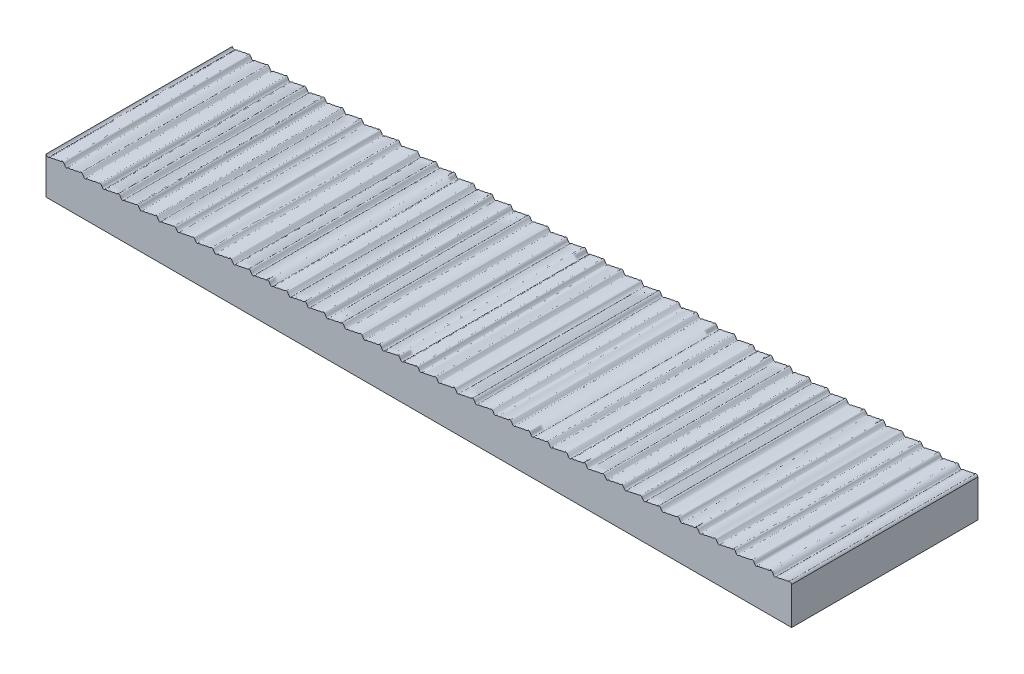
from build123d import *

# Parameters (mm, degrees)
AUFSATZ_LINEAR_AUSTRAGEN1_DEPTH = 50


with BuildPart() as part:
    # Skizze1 → Aufsatz-Linear austragen1 (new body)
    with BuildSketch(Plane.XY):
        with BuildLine():
            Line((0, 10), (0, 0))
            Line((0, 0), (200, 0))
            Line((200, 0), (200, 10))
            add(Edge.make_bspline(
                [(0, 10), (0.032006504, 9.947251725), (0.096257273, 9.839130988), (0.234909001, 9.611414135), (0.499662737, 9.425076683), (0.843522161, 9.651124983), (1.112437897, 9.835883165), (1.501650386, 9.736238413), (1.805748065, 9.815309142), (2.054364451, 9.941510427), (2.305494291, 10.007611652), (2.578672342, 9.99534574), (2.877842259, 10.015980332), (3.189051168, 10.200216604), (3.548975528, 10.264656199), (4.006052231, 10.149740183), (4.283292665, 10.532842136), (4.70199408, 10.516818743), (4.882215848, 10.161704391), (5.060681148, 9.933910956), (5.199674852, 9.631251905), (5.506445935, 9.411278935), (5.820888943, 9.640877582), (6.091719409, 9.814635092), (6.458189596, 9.755166071), (6.796212128, 9.786573828), (7.119360934, 9.996462894), (7.488800036, 10.003383695), (7.858830243, 9.993648069), (8.19220552, 10.208222573), (8.540894832, 10.250582735), (8.949614043, 10.173687554), (9.214558457, 10.416007843), (9.580028868, 10.587783918), (9.843255258, 10.271931735), (9.998865934, 10.002190322), (10.156265981, 9.727950643), (10.423156059, 9.406839859), (10.788569526, 9.590006508), (11.055060475, 9.822527482), (11.449757984, 9.75198322), (11.794839609, 9.786834881), (12.124601512, 9.99796634), (12.493867467, 10.002466767), (12.863746765, 9.995305922), (13.196790371, 10.211052702), (13.546238484, 10.249166052), (13.954813763, 10.174346647), (14.218309579, 10.421386455), (14.586305585, 10.585924869), (14.845207018, 10.266320448), (15.002081262, 9.998726175), (15.158240093, 9.722236402), (15.429499905, 9.405226405), (15.792242493, 9.595384618), (16.060219144, 9.823030322), (16.455035893, 9.75075919), (16.799292223, 9.789289436), (17.129237167, 9.999939729), (17.498560828, 10.001143074), (17.868527928, 9.997386953), (18.199879635, 10.212724455), (18.552541759, 10.24914575), (18.955719966, 10.172836242), (19.223228528, 10.427316624), (19.592237888, 10.583742354), (19.847243084, 10.26082626), (20.005237888, 9.995261693), (20.160246492, 9.716510947), (20.43584548, 9.403781209), (20.79585148, 9.600724987), (21.065439586, 9.823474914), (21.460285139, 9.749528548), (21.803937226, 9.7918642), (22.133929111, 10.001897517), (22.503936402, 9.999910088), (22.873274711, 9.999338831), (23.204548574, 10.215354943), (23.557907755, 10.247756035), (23.960818974, 10.173573184), (24.227019016, 10.432661195), (24.598402046, 10.581580395), (24.849117158, 10.255360884), (25.00842879, 9.991822389), (25.16225555, 9.710769778), (25.442200713, 9.402503704), (25.799399192, 9.606028807), (26.070703013, 9.823848426), (26.465506362, 9.748329946), (26.808583447, 9.794484213), (27.138630105, 10.003795563), (27.509306886, 9.998679315), (27.87800526, 10.001347533), (28.20921081, 10.217931096), (28.563280997, 10.24633683), (28.965848264, 10.174401049), (29.230849402, 10.437974877), (29.604499382, 10.57927456), (29.850962716, 10.249968515), (30.01160145, 9.988392506), (30.164288173, 9.70501997), (30.448553492, 9.401390586), (30.802893507, 9.611294102), (31.076004936, 9.824151827), (31.470702058, 9.747164541), (31.813229902, 9.79714856), (32.143341397, 10.005633237), (32.514672058, 9.997452481), (32.882720389, 10.003412166), (33.213866689, 10.220452414), (33.568662197, 10.244889377), (33.970807964, 10.175320484), (34.234721349, 10.443254274), (34.610528232, 10.576827865), (34.852782892, 10.2446498), (35.014754443, 9.984969669), (35.166346129, 9.699264863), (35.454901561, 9.400439093), (35.806335276, 9.616520525), (36.081348032, 9.824380909), (36.475864776, 9.746044568), (36.817892677, 9.799834446), (37.148033402, 10.007451205), (37.52008768, 9.996155468), (37.887318995, 10.00567065), (38.218701879, 10.222665356), (38.573720388, 10.243871409), (38.976264247, 10.175536109), (39.240682486, 10.452714148), (39.63069245, 10.575993721), (39.866524321, 10.211625688), (40.038261817, 9.958540442), (40.192105017, 9.637425717), (40.516755211, 9.403915112), (40.835542888, 9.659766155), (41.110808095, 9.814575398), (41.492912913, 9.748386662), (41.825623928, 9.803614948), (42.152961569, 10.009790072), (42.525340169, 9.994608817), (42.892067423, 10.008023777), (43.223298761, 10.224978386), (43.57917124, 10.242424005), (43.981013403, 10.176612548), (44.244730396, 10.457962252), (44.636451549, 10.572950322), (44.868179201, 10.206540324), (45.041190165, 9.955296565), (45.194610516, 9.63163098), (45.522883436, 9.404672173), (45.838727237, 9.66425471), (46.116375986, 9.814626257), (46.497835276, 9.7473727), (46.830324953, 9.806461319), (47.157694931, 10.011363491), (47.530656578, 9.993515394), (47.896832636, 10.010065931), (48.227755182, 10.227659484), (48.5849172, 10.240315518), (48.985192422, 10.178823417), (49.245896669, 10.457675642), (49.624367556, 10.568251335), (49.854430915, 10.236912858), (50.018828067, 9.981069239), (50.16602851, 9.698190142), (50.457686522, 9.400520554), (50.809516387, 9.615688099), (51.085907118, 9.829027423), (51.490397123, 9.741234621), (51.829282122, 9.808194156), (52.163129179, 10.01202536), (52.535628561, 9.992818249), (52.901695338, 10.01207691), (53.232284965, 10.23010355), (53.590387807, 10.238687664), (53.989864633, 10.180157454), (54.249941388, 10.462759024), (54.630143428, 10.56537252), (54.856224017, 10.23184705), (55.021946657, 9.977597647), (55.168121767, 9.692491152), (55.463956001, 9.399652915), (55.813099517, 9.621171333), (56.091222935, 9.828898971), (56.495555261, 9.740291735), (56.833891822, 9.811022957), (57.167921739, 10.013579132), (57.540960558, 9.991622376), (57.906347312, 10.014414893), (58.236919824, 10.232341643), (58.595811507, 10.237118366), (58.994501386, 10.181542877), (59.254021541, 10.467812169), (59.635852245, 10.562357705), (59.858000604, 10.22685641), (60.025040742, 9.974128005), (60.170246509, 9.686791865), (60.47021242, 9.39893872), (60.816633001, 9.626621924), (61.096582329, 9.828704093), (61.500685751, 9.739387323), (61.838506137, 9.81389124), (62.172726416, 10.015069339), (62.546289783, 9.990440558), (62.910987899, 10.016803239), (63.241552422, 10.234523139), (63.601247651, 10.235527922), (63.999072962, 10.183022763), (64.258151841, 10.472814033), (64.64148673, 10.559218744), (64.8597674, 10.221935058), (65.028107334, 9.970661043), (65.172405755, 9.681093113), (65.476453034, 9.3983772), (65.820119762, 9.632036163), (66.101983594, 9.828445037), (66.505789816, 9.73852177), (66.843124991, 9.81679828), (67.177543964, 10.016495498), (67.551616529, 9.989274474), (67.915618038, 10.019240979), (68.246183563, 10.236647951), (68.606697143, 10.233917395), (69.003580617, 10.184597619), (69.262333703, 10.477762024), (69.647046328, 10.555958347), (69.861527334, 10.217082084), (70.031145399, 9.967194935), (70.174601832, 9.675396607), (70.48267563, 9.397967002), (70.823562549, 9.637410917), (71.107425211, 9.82812376), (71.51086862, 9.737695613), (71.847748379, 9.819743235), (72.182375094, 10.017857214), (72.55694115, 9.988125762), (72.920238675, 10.021727146), (73.25081416, 10.238716053), (73.612160836, 10.232287767), (74.008025898, 10.186268078), (74.266568295, 10.482653455), (74.652531021, 10.552579474), (74.863282502, 10.212295667), (75.034155979, 9.963729641), (75.176833084, 9.6697003), (75.488884915, 9.397712934), (75.8269504, 9.642730602), (76.112927215, 9.827761935), (76.515927187, 9.736857693), (76.85257986, 9.822843125), (77.187301465, 10.019153241), (77.563005295, 9.987116026), (77.924920278, 10.024097941), (78.256907569, 10.241787102), (78.618032277, 10.229501821), (79.01020157, 10.187182783), (79.271726339, 10.487852673), (79.657383553, 10.548899091), (79.865344146, 10.207712749), (80.036981914, 9.96019081), (80.179168024, 9.664039377), (80.495033877, 9.397586942), (80.830335836, 9.648027517), (81.118430129, 9.827315577), (81.520971165, 9.736115182), (81.857207079, 9.825862098), (82.192183116, 10.020389304), (82.568324847, 9.98599945), (82.92957705, 10.026699464), (83.261510916, 10.243738176), (83.623650779, 10.227839022), (84.014541356, 10.1890433), (84.276044683, 10.492620728), (84.662728148, 10.545294425), (84.867093003, 10.203055696), (85.039933116, 9.956717079), (85.181487399, 9.658358599), (85.501191096, 9.397622383), (85.833664215, 9.65326698), (86.123983001, 9.826818789), (86.525985707, 9.735410389), (86.861842942, 9.828918057), (87.197078339, 10.021558938), (87.573643321, 9.984905248), (87.934227757, 10.029347537), (88.266113659, 10.24562967), (88.629288515, 10.226163226), (89.018828242, 10.191001978), (89.28041781, 10.497325227), (89.667998685, 10.54157848), (89.868845109, 10.198461429), (90.042854, 9.953236479), (90.183851213, 9.652686735), (90.507325927, 9.397802147), (90.836954453, 9.658459119), (91.129579527, 9.826262743), (91.530981444, 9.734751727), (91.866568907, 9.832008601), (92.202024048, 10.022754973), (92.57927551, 9.983709242), (92.938887147, 10.032295526), (93.271412763, 10.247371771), (93.634698941, 10.224684825), (94.024438526, 10.193019481), (94.284228129, 10.500966232), (94.672836498, 10.538947466), (94.870983673, 10.192894324), (95.045474313, 9.950893312), (95.186451893, 9.645352944), (95.513216956, 9.400765749), (95.840590578, 9.658352355), (96.134673857, 9.833470046), (96.57393839, 9.709236266), (96.957302379, 9.908745983), (97.40270625, 10.048956494), (97.928024772, 9.950545397), (98.349048217, 10.370609416), (98.939332984, 10.05474952), (99.271360932, 10.562376312), (99.739708775, 10.498649332), (99.914320879, 10.10260444), (100.085437404, 9.897448643), (100.253409945, 9.513710136), (100.708786446, 9.426753666), (101.034006655, 9.929697391), (101.602809116, 9.642202071), (102.029671442, 10.005115914), (102.541602513, 9.984815941), (102.992435817, 10.04024688), (103.365631293, 10.290547322), (103.763984642, 10.183377678), (104.091381715, 10.263408161), (104.334474016, 10.528669736), (104.679584539, 10.505757555), (104.849646517, 10.231328695), (105.00991329, 9.998075433), (105.141182041, 9.748181714), (105.471987687, 9.317868095), (105.890747355, 9.762249419), (106.304062235, 9.803711789), (106.822914218, 9.738108925), (107.197672748, 10.080986538), (107.686468421, 9.932823858), (108.083521136, 10.139724741), (108.471321242, 10.285040613), (108.932790429, 10.142546045), (109.216105566, 10.430918395), (109.589600053, 10.57543281), (109.831379568, 10.283226944), (109.987121524, 10.023935445), (110.122963481, 9.787208471), (110.459770924, 9.300129694), (110.891396856, 9.782048104), (111.342971404, 9.774611498), (111.879621083, 9.781247689), (112.301756379, 10.099789764), (112.819437594, 9.917828042), (113.191614997, 10.240818263), (113.592405759, 10.231868939), (113.984304944, 10.184059004), (114.245363149, 10.452251334), (114.596490748, 10.560631646), (114.823845372, 10.296772049), (114.971197633, 10.038505341), (115.117673915, 9.820462108), (115.358961014, 9.402685254), (115.794095179, 9.562104604), (116.119686962, 9.88998864), (116.64444119, 9.668827759), (117.020655756, 9.981070193), (117.467593493, 10.009977247), (117.917214712, 9.987974235), (118.272351827, 10.287327021), (118.749497926, 10.179211676), (119.114002086, 10.268822235), (119.548301687, 10.693132929), (119.952611834, 10.136418099), (120.051827511, 9.853711324), (120.459900649, 9.315281049), (120.880328307, 9.72983327), (121.253323286, 9.821891177), (121.741132051, 9.711369528), (122.100031258, 10.026184943), (122.556452978, 9.979768132), (122.993482416, 10.036394755), (123.366477412, 10.323884456), (123.881589525, 10.115962447), (124.200323653, 10.432226687), (124.634012011, 10.59872357), (124.878204442, 10.192642685), (125.021160345, 9.968565333), (125.171968126, 9.716996374), (125.371537002, 9.461678194), (125.700875263, 9.51300078), (125.928415003, 9.743211303), (126.240918544, 9.810660998), (126.611635504, 9.718294089), (126.987463931, 9.930830636), (127.415743244, 10.036671666), (127.945691446, 9.964795623), (128.357445646, 10.365028788), (128.945607862, 10.065906609), (129.266995297, 10.539218696), (129.724156058, 10.520641079), (129.90122588, 10.108873032), (130.077449003, 9.930625787), (130.23482389, 9.528282978), (130.693124608, 9.408931816), (131.036549038, 9.941982296), (131.611703729, 9.633468088), (132.044228921, 10.02086386), (132.559759209, 9.973297227), (133.002968416, 10.055381507), (133.377081663, 10.284779524), (133.762174757, 10.188972346), (134.083009984, 10.255483443), (134.326742041, 10.516256564), (134.672556037, 10.519428907), (134.860076683, 10.220720041), (135.01233447, 9.982781206), (135.15734065, 9.741753034), (135.346750871, 9.483878805), (135.642705201, 9.49044236), (135.857128188, 9.673476652), (136.147308431, 9.834493897), (136.562058807, 9.694534144), (136.958623655, 9.925740033), (137.444046759, 10.032711656), (137.916233012, 9.981930399), (138.281056416, 10.264763457), (138.666427574, 10.223406511), (139.007568988, 10.188684927), (139.302607847, 10.546174374), (139.773151166, 10.491430982), (139.989497352, 10.011258982), (140.196171782, 9.562814631), (140.705439274, 9.399291634), (141.039759143, 9.911044121), (141.523656371, 9.682393196), (141.922288967, 9.885106234), (142.321276668, 10.044845324), (142.784527788, 9.949236801), (143.158978767, 10.201724266), (143.598121795, 10.265508461), (144.040549762, 10.143364423), (144.399759268, 10.671164894), (144.892831393, 10.298979846), (145.016741729, 9.925564701), (145.352623605, 9.360442884), (145.839097764, 9.613659184), (146.168663108, 9.867844386), (146.63470124, 9.690771002), (146.993017248, 9.945769168), (147.415057762, 10.032314755), (147.891540164, 9.952520733), (148.269888975, 10.316440488), (148.797066648, 10.142593275), (149.165660529, 10.340677003), (149.570699573, 10.640380189), (149.8696045, 10.227231193), (149.997336249, 9.996818736), (150.157661362, 9.747791498), (150.349997397, 9.466873426), (150.703577992, 9.501275962), (150.951883187, 9.77527733), (151.308881027, 9.800525786), (151.706006972, 9.717413546), (152.079566149, 10.02293575), (152.553796109, 9.964602957), (153.041057448, 10.075370496), (153.436423677, 10.304381079), (153.853153002, 10.166293147), (154.143108924, 10.326155729), (154.359293192, 10.51163035), (154.657337479, 10.514200572), (154.844648085, 10.253895109), (154.99403178, 10.008670195), (155.140855446, 9.772630641), (155.355095054, 9.450507434), (155.734058794, 9.51410509), (156.003582044, 9.83180516), (156.426731009, 9.752615471), (156.828259089, 9.781421726), (157.205498508, 10.071338102), (157.69907491, 9.919963036), (158.109637882, 10.185162661), (158.600689486, 10.262843514), (159.072426711, 10.149416529), (159.445491981, 10.679649339), (159.832232456, 10.324220775), (159.951448601, 10.046041142), (160.129962995, 9.81707619), (160.268155213, 9.54422652), (160.596139891, 9.441333538), (160.851271416, 9.676873149), (161.134928006, 9.817249259), (161.523513462, 9.73068101), (161.907527106, 9.852439312), (162.32617136, 10.073139619), (162.857696163, 9.924026185), (163.23879483, 10.278757927), (163.634802079, 10.205086883), (163.968841954, 10.225860965), (164.192200194, 10.364331389), (164.445625536, 10.558206449), (164.747424187, 10.43779594), (164.89395375, 10.151079166), (165.071619648, 9.914810714), (165.217116678, 9.573310898), (165.655394007, 9.377862187), (165.984939435, 9.909029219), (166.525591387, 9.66728253), (166.974298892, 9.936136962), (167.459739518, 10.029120905), (167.934552705, 9.985258574), (168.302752365, 10.285675334), (168.70179555, 10.195485594), (169.05185964, 10.231514454), (169.293680084, 10.49648898), (169.63829208, 10.535174101), (169.837729698, 10.263750674), (169.978141135, 10.033816459), (170.130013446, 9.798129016), (170.340516556, 9.436022025), (170.762489338, 9.523336114), (171.064280549, 9.873227311), (171.544958363, 9.696605379), (171.932922654, 9.888321739), (172.33810762, 10.045421283), (172.789923217, 9.953303182), (173.161412815, 10.196576954), (173.583980843, 10.273173247), (174.029758036, 10.129254137), (174.391739523, 10.678254919), (174.893944244, 10.295969619), (175.021204267, 9.920724517), (175.375135908, 9.341658478), (175.850717887, 9.646889812), (176.196983536, 9.853042324), (176.649869602, 9.698417839), (177.005323763, 9.949503121), (177.414620452, 10.031486185), (177.872818209, 9.953165971), (178.234181856, 10.289727826), (178.746557971, 10.166912599), (179.130189466, 10.291040748), (179.566697224, 10.673173686), (179.875414098, 10.210196881), (180.02024286, 9.966163928), (180.175094353, 9.704917882), (180.407782088, 9.435505872), (180.747378351, 9.550829682), (180.988619123, 9.787956672), (181.346246424, 9.790456679), (181.728792916, 9.728793705), (182.094182171, 10.029900231), (182.567081039, 9.959041593), (183.044580468, 10.084438801), (183.487291457, 10.323196561), (184.014302289, 10.102121672), (184.325568541, 10.589293227), (184.746935516, 10.46427765), (184.896575669, 10.135843005), (185.069936716, 9.916406655), (185.202118045, 9.61124917), (185.613995595, 9.353673765), (185.950525418, 9.882652562), (186.470329619, 9.694470427), (186.938253977, 9.885004271), (187.405092251, 10.05655071), (187.893172995, 9.956039127), (188.261063696, 10.272510477), (188.655727755, 10.209175321), (189.021734523, 10.209811252), (189.265374458, 10.477061857), (189.633296474, 10.551329729), (189.842077086, 10.252565922), (190.011060971, 9.998813515), (190.139686592, 9.736897823), (190.462788033, 9.357264859), (190.859305867, 9.690473232), (191.220097976, 9.8426349), (191.72977248, 9.695739066), (192.100203207, 10.032249234), (192.564358452, 9.978915584), (192.996019839, 10.036565766), (193.358073348, 10.323208541), (193.848821363, 10.115372614), (194.182764099, 10.413924524), (194.656166808, 10.61983372), (194.973230201, 10.063860366), (195.108652307, 9.743608962), (195.557037868, 9.309084005), (195.947795495, 9.840466199), (196.359046221, 9.752251964), (196.820869164, 9.771971549), (197.186746278, 10.060821749), (197.692728609, 9.935441925), (198.093901849, 10.157622059), (198.584160366, 10.292537736), (199.052550528, 10.113595759), (199.482340952, 10.767783498), (199.837329562, 10.268801828), (199.945784883, 10.089349152), (200, 10)],
                knots=[0.083345276, 0.083345276, 0.083345276, 0.083345276, 0.083345276, 0.084435193, 0.08552511, 0.086615027, 0.087704944, 0.089654113, 0.090628697, 0.091603281, 0.092577866, 0.09355245, 0.094527035, 0.095501619, 0.09703038, 0.09855914, 0.100087901, 0.101616661, 0.102786314, 0.103955967, 0.10512562, 0.106295272, 0.107517883, 0.108740495, 0.109963106, 0.111185717, 0.112533725, 0.113881733, 0.115229742, 0.11657775, 0.117925758, 0.119273766, 0.120621774, 0.121969783, 0.123182826, 0.124395869, 0.125608913, 0.126821956, 0.128124528, 0.129427101, 0.130729674, 0.132032246, 0.133380327, 0.134728409, 0.13607649, 0.137424571, 0.138772653, 0.140120734, 0.141468815, 0.142816897, 0.144029995, 0.145243094, 0.146456193, 0.147669292, 0.148971631, 0.15027397, 0.151576309, 0.152878648, 0.154226252, 0.155573857, 0.156921462, 0.158269067, 0.159616672, 0.160964277, 0.162311882, 0.163659487, 0.164872636, 0.166085785, 0.167298934, 0.168512083, 0.169814217, 0.171116351, 0.172418484, 0.173720618, 0.175068292, 0.176415966, 0.17776364, 0.179111314, 0.180458988, 0.181806662, 0.183154336, 0.18450201, 0.185715203, 0.186928396, 0.18814159, 0.189354783, 0.190656741, 0.191958698, 0.193260656, 0.194562614, 0.195910344, 0.197258074, 0.198605804, 0.199953534, 0.201301264, 0.202648994, 0.203996724, 0.205344454, 0.206557684, 0.207770915, 0.208984146, 0.210197376, 0.211499188, 0.212800999, 0.21410281, 0.215404622, 0.216752395, 0.218100168, 0.219447941, 0.220795714, 0.222143487, 0.22349126, 0.224839033, 0.226186807, 0.227400067, 0.228613327, 0.229826587, 0.231039848, 0.232341543, 0.233643238, 0.234944933, 0.236246627, 0.237594431, 0.238942235, 0.240290038, 0.241637842, 0.242985645, 0.244333449, 0.245681252, 0.247029056, 0.248299695, 0.249570333, 0.250840972, 0.25211161, 0.253356736, 0.254601861, 0.255846987, 0.257092112, 0.258439934, 0.259787756, 0.261135577, 0.262483399, 0.263831221, 0.265179042, 0.266526864, 0.267874685, 0.269145159, 0.270415632, 0.271686105, 0.272956579, 0.274201863, 0.275447147, 0.27669243, 0.277937714, 0.279285542, 0.280633369, 0.281981197, 0.283329025, 0.284676852, 0.28602468, 0.287372507, 0.288720335, 0.289917447, 0.29111456, 0.292311673, 0.293508785, 0.294827513, 0.296146242, 0.29746497, 0.298783698, 0.300131519, 0.301479341, 0.302827163, 0.304174985, 0.305522806, 0.306870628, 0.30821845, 0.309566272, 0.310763446, 0.311960621, 0.313157796, 0.314354971, 0.315673711, 0.316992451, 0.318311191, 0.319629931, 0.320977735, 0.32232554, 0.323673344, 0.325021149, 0.326368954, 0.327716758, 0.329064563, 0.330412367, 0.331609591, 0.332806814, 0.334004037, 0.33520126, 0.336520042, 0.337838824, 0.339157607, 0.340476389, 0.341824165, 0.343171942, 0.344519719, 0.345867495, 0.347215272, 0.348563048, 0.349910825, 0.351258602, 0.352455858, 0.353653115, 0.354850372, 0.356047629, 0.357366484, 0.358685338, 0.360004193, 0.361323048, 0.362670786, 0.364018525, 0.365366263, 0.366714001, 0.368061739, 0.369409477, 0.370757216, 0.372104954, 0.373302229, 0.374499504, 0.375696779, 0.376894054, 0.378213011, 0.379531969, 0.380850927, 0.382169885, 0.383517575, 0.384865265, 0.386212955, 0.387560645, 0.388908335, 0.390256025, 0.391603715, 0.392951405, 0.394148682, 0.395345959, 0.396543236, 0.397740512, 0.399059603, 0.400378693, 0.401697784, 0.403016874, 0.404365142, 0.405713409, 0.407061677, 0.408409944, 0.409758212, 0.411106479, 0.412454747, 0.413803014, 0.415000276, 0.416197537, 0.417394799, 0.418592061, 0.419911313, 0.421230566, 0.422549818, 0.423869071, 0.425217296, 0.426565521, 0.427913746, 0.429261971, 0.430610196, 0.431958422, 0.433306647, 0.434654872, 0.435852101, 0.437049329, 0.438246558, 0.439443787, 0.44076323, 0.442082674, 0.443402117, 0.44472156, 0.446069735, 0.447417909, 0.448766084, 0.450114258, 0.451462432, 0.452810607, 0.454158781, 0.455506955, 0.456704133, 0.45790131, 0.459098488, 0.460295665, 0.461615328, 0.46293499, 0.464254652, 0.465574314, 0.466922698, 0.468271081, 0.469619465, 0.470967848, 0.472316231, 0.473664615, 0.475012998, 0.476361382, 0.477558489, 0.478755596, 0.479952703, 0.48114981, 0.482469719, 0.483789627, 0.485109535, 0.486429443, 0.488266366, 0.490103289, 0.491940212, 0.493777134, 0.495699362, 0.497621589, 0.498771766, 0.499921942, 0.501072119, 0.502222295, 0.504055794, 0.505889293, 0.507726385, 0.509563476, 0.511400567, 0.513237659, 0.514473834, 0.515710008, 0.516946183, 0.518182358, 0.519207734, 0.520233109, 0.521258485, 0.52228386, 0.524122215, 0.52596057, 0.527642769, 0.529324968, 0.531007167, 0.532689366, 0.53419755, 0.535705735, 0.537213919, 0.538722104, 0.53980497, 0.540887837, 0.541970703, 0.54305357, 0.544925205, 0.54679684, 0.548632636, 0.550468431, 0.552304227, 0.554140022, 0.555496009, 0.556851996, 0.558207983, 0.55956397, 0.560614574, 0.561665178, 0.562715782, 0.563766386, 0.565365751, 0.566965116, 0.568621985, 0.570278854, 0.571935724, 0.573592593, 0.575136685, 0.576680776, 0.578224868, 0.579768959, 0.581547766, 0.583326572, 0.585015854, 0.586705136, 0.588292284, 0.589879433, 0.591466581, 0.593053729, 0.594678512, 0.596303296, 0.597928079, 0.599552862, 0.601145006, 0.602737151, 0.603778359, 0.604819566, 0.605860774, 0.606901982, 0.608053129, 0.609204277, 0.610355424, 0.611506572, 0.613344358, 0.615182143, 0.617019929, 0.618857714, 0.620715485, 0.622573256, 0.62371206, 0.624850863, 0.625989667, 0.62712847, 0.629045857, 0.630963243, 0.632800891, 0.63463854, 0.636476188, 0.638313836, 0.639513311, 0.640712785, 0.64191226, 0.643111734, 0.644212442, 0.645313151, 0.646413859, 0.647514567, 0.648490259, 0.649465951, 0.650441643, 0.651417335, 0.65325475, 0.655092166, 0.656929581, 0.658766996, 0.659992867, 0.661218738, 0.66244461, 0.663670481, 0.665596957, 0.667523434, 0.669197491, 0.670871549, 0.672458693, 0.674045838, 0.675632982, 0.677220127, 0.678807943, 0.680395759, 0.681983575, 0.68357139, 0.685256227, 0.686941065, 0.68885662, 0.690772176, 0.692249696, 0.693727215, 0.695204734, 0.696682253, 0.698387897, 0.700093542, 0.701799186, 0.70350483, 0.705137431, 0.706770031, 0.707826415, 0.708882799, 0.709939184, 0.710995568, 0.712279424, 0.713563281, 0.714847137, 0.716130993, 0.717968655, 0.719806317, 0.72164398, 0.723481642, 0.724461904, 0.725442166, 0.726422428, 0.72740269, 0.728513523, 0.729624357, 0.73073519, 0.731846023, 0.733279451, 0.734712879, 0.736146308, 0.737579736, 0.739316499, 0.741053263, 0.742790026, 0.74452679, 0.74635965, 0.74819251, 0.749231711, 0.750270912, 0.751310112, 0.752349313, 0.753519923, 0.754690534, 0.755861144, 0.757031754, 0.758869761, 0.760707769, 0.762545776, 0.764383784, 0.765380404, 0.766377023, 0.767373643, 0.768370263, 0.769512184, 0.770654105, 0.771796026, 0.772937947, 0.774716475, 0.776495004, 0.77833286, 0.780170717, 0.782008574, 0.783846431, 0.785114162, 0.786381892, 0.787649623, 0.788917353, 0.78993824, 0.790959127, 0.791980013, 0.7930009, 0.79447521, 0.79594952, 0.797537726, 0.799125932, 0.800714138, 0.802302344, 0.80384913, 0.805395916, 0.806942702, 0.808489489, 0.810254299, 0.81201911, 0.813945649, 0.815872188, 0.817344004, 0.818815819, 0.820287635, 0.82175945, 0.823380146, 0.825000841, 0.826621536, 0.828242232, 0.830053646, 0.831865061, 0.832959288, 0.834053514, 0.835147741, 0.836241968, 0.837483201, 0.838724433, 0.839965666, 0.841206899, 0.843029967, 0.844853036, 0.846676104, 0.848499172, 0.850194616, 0.85189006, 0.852952976, 0.854015892, 0.855078809, 0.856141725, 0.857906679, 0.859671634, 0.861508809, 0.863345984, 0.865183159, 0.867020335, 0.868304094, 0.869587854, 0.870871614, 0.872155373, 0.873281614, 0.874407855, 0.875534095, 0.876660336, 0.878259022, 0.879857709, 0.88151173, 0.883165751, 0.884819772, 0.886473793, 0.888021855, 0.889569917, 0.891117978, 0.89266604, 0.894441298, 0.896216555, 0.897907271, 0.899597987, 0.90118168, 0.902765372, 0.904349064, 0.905932757, 0.907690155, 0.909447553, 0.911204952, 0.91296235, 0.914808537, 0.916654723, 0.916654723, 0.916654723, 0.916654723, 0.916654723], degree=4))
        make_face()
    extrude(amount=AUFSATZ_LINEAR_AUSTRAGEN1_DEPTH)


solid = part.part
